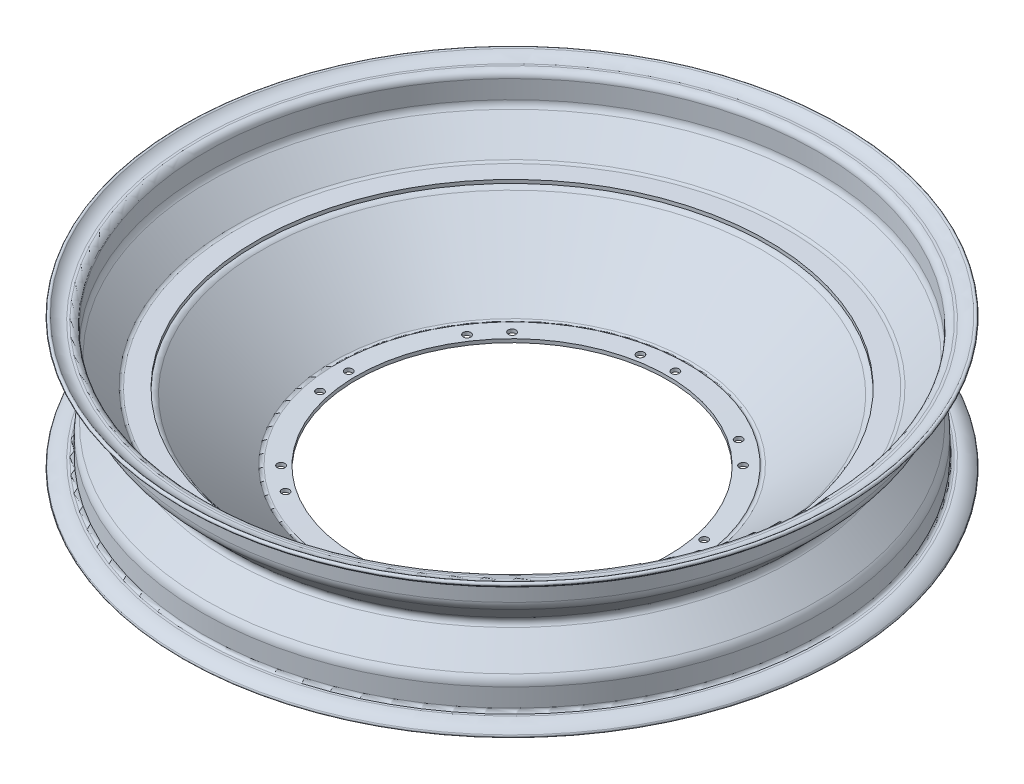
from build123d import *

# Parameters (mm, degrees)
SKETCH4_R               = 2.5
CUT_EXTRUDE3_DEPTH      = 41.899911875
CUT_EXTRUDE3_DEPTH_BACK = 48.292859511


with BuildPart() as part:
    # Sketch3 → Revolve2 (revolve)
    with BuildSketch(Plane.XY):
        with BuildLine():
            Line((-206.357183565, 37.167999668), (-204.857183475, 37.167999668))
            ThreePointArc((-204.857183475, 37.167999668), (-201.826523811, 35.912659332), (-200.571183475, 32.881999668))
            Line((-200.571183475, 32.881999668), (-200.571183475, 20.882001784))
            ThreePointArc((-200.571183475, 20.882001784), (-200.105263944, 18.622035193), (-198.783487479, 16.73062382))
            Line((-198.783487479, 16.73062382), (-182.043522604, -0.008977596))
            ThreePointArc((-182.043522604, -0.008977596), (-181.127338782, -0.617478113), (-180.048425839, -0.831049034))
            Line((-180.048425839, -0.831049034), (-167.29030635, -0.831049034))
            Line((-167.29030635, -0.831049034), (-167.290309661, -3.117049034))
            ThreePointArc((-167.290309661, -3.117049034), (-165.433325795, -3.465644725), (-163.82919026, -4.463971934))
            Line((-163.82919026, -4.463971934), (-117.404080958, -44.521079622))
            ThreePointArc((-117.404080958, -44.521079622), (-116.187448684, -45.004834199), (-114.932257648, -44.63239891))
            Line((-114.932257648, -44.63239891), (-102.000000909, -45.005569111))
            Line((-102.000000909, -45.005569111), (-102.000000909, -47.292520638))
            Line((-102.000000909, -47.292520638), (-114.383374161, -46.935188891))
            ThreePointArc((-114.383374161, -46.935188891), (-116.738970515, -47.244580095), (-118.897459215, -46.251864814))
            Line((-118.897459215, -46.251864814), (-165.352696521, -6.168761697))
            ThreePointArc((-165.352696521, -6.168761697), (-166.248595002, -5.601418118), (-167.29030635, -5.403049034))
            Line((-167.29030635, -5.403049034), (-180.048425839, -5.403049034))
            ThreePointArc((-180.048425839, -5.403049034), (-181.132186287, -5.618622356), (-182.050954083, -6.232523248))
            Line((-182.050954083, -6.232523248), (-198.81744055, -22.99900562))
            ThreePointArc((-198.81744055, -22.99900562), (-200.114496487, -24.879602157), (-200.571182545, -27.118002318))
            Line((-200.571182545, -27.118002318), (-200.571182545, -39.117999415))
            ThreePointArc((-200.571182545, -39.117999415), (-201.826522955, -42.148659258), (-204.857182798, -43.403999668))
            Line((-204.857182798, -43.403999668), (-206.357183565, -43.403999668))
            ThreePointArc((-206.357183565, -43.403999668), (-210.497320896, -44.280705684), (-213.926731129, -46.760321785))
            ThreePointArc((-213.926731129, -46.760321785), (-215.541213082, -46.839983719), (-215.620875016, -45.225501766))
            ThreePointArc((-215.620875016, -45.225501766), (-211.423926917, -42.190921656), (-206.357183565, -41.117999668))
            Line((-206.357183565, -41.117999668), (-204.857182798, -41.117999668))
            ThreePointArc((-204.857182798, -41.117999668), (-203.442969057, -40.532213156), (-202.857182545, -39.117999415))
            Line((-202.857182545, -39.117999415), (-202.857182545, -27.118001297))
            ThreePointArc((-202.857182545, -27.118001297), (-202.222549038, -23.995285341), (-200.419340997, -21.368013867))
            Line((-200.419340997, -21.368013867), (-184.996799867, -5.945476504))
            ThreePointArc((-184.996799867, -5.945476504), (-183.825226646, -3.117027566), (-184.996830227, -0.288591203))
            Line((-184.996830227, -0.288591203), (-200.37929842, 15.093543005))
            ThreePointArc((-200.37929842, 15.093543005), (-202.211669172, 17.733741575), (-202.857183475, 20.882001784))
            Line((-202.857183475, 20.882001784), (-202.857183475, 32.881999668))
            ThreePointArc((-202.857183475, 32.881999668), (-203.442969913, 34.296213231), (-204.857183475, 34.881999668))
            Line((-204.857183475, 34.881999668), (-206.357183565, 34.881999668))
            ThreePointArc((-206.357183565, 34.881999668), (-211.423926917, 35.954921656), (-215.620875016, 38.989501766))
            ThreePointArc((-215.620875016, 38.989501766), (-215.541213082, 40.603983719), (-213.926731129, 40.524321785))
            ThreePointArc((-213.926731129, 40.524321785), (-210.497320896, 38.044705684), (-206.357183565, 37.167999668))
        make_face()
    revolve(axis=Axis((0, 240.888952165, 0), (0, -1, 0)))

    # Sketch4 → Cut-Extrude3 (cut, two sides)
    with BuildSketch(Plane(origin=(0, 0, 0), x_dir=(1, 0, 0), z_dir=(0, 1, 0))) as cut_extrude3_sk:
        with Locations((0, 107)):
            Circle(SKETCH4_R)
        with Locations((-3884.181572475, -9484.24383099)):
            Circle(SKETCH4_R)
        with Locations((-13412.746254639, -13519.746254639)):
            Circle(SKETCH4_R)
        with Locations((-23003.990085629, -9635.564682164)):
            Circle(SKETCH4_R)
        with Locations((-27039.492509279, -107)):
            Circle(SKETCH4_R)
        with Locations((-23155.310936803, 9484.24383099)):
            Circle(SKETCH4_R)
        with Locations((-13626.746254639, 13519.746254639)):
            Circle(SKETCH4_R)
        with Locations((-4035.502423649, 9635.564682164)):
            Circle(SKETCH4_R)
        with Locations((-20.874664456, 104.944025003)):
            Circle(SKETCH4_R)
        with Locations((-3900.395983129, -9470.93700806)):
            Circle(SKETCH4_R)
        with Locations((-13414.802229636, -13498.871590184)):
            Circle(SKETCH4_R)
        with Locations((-22990.6832627, -9619.35027151)):
            Circle(SKETCH4_R)
        with Locations((-27018.617844823, -104.944025003)):
            Circle(SKETCH4_R)
        with Locations((-23139.096526149, 9470.93700806)):
            Circle(SKETCH4_R)
        with Locations((-13624.690279642, 13498.871590184)):
            Circle(SKETCH4_R)
        with Locations((-4048.809246579, 9619.35027151)):
            Circle(SKETCH4_R)
        with Locations((75.660425587, 75.660425587)):
            Circle(SKETCH4_R)
        with Locations((59.446014933, 88.967248516)):
            Circle(SKETCH4_R)
        with Locations((107, 0)):
            Circle(SKETCH4_R)
        with Locations((104.944025003, 20.874664456)):
            Circle(SKETCH4_R)
        with Locations((75.660425587, -75.660425587)):
            Circle(SKETCH4_R)
        with Locations((88.967248516, -59.446014933)):
            Circle(SKETCH4_R)
        with Locations((0, -107)):
            Circle(SKETCH4_R)
        with Locations((20.874664456, -104.944025003)):
            Circle(SKETCH4_R)
        with Locations((-75.660425587, -75.660425587)):
            Circle(SKETCH4_R)
        with Locations((-59.446014933, -88.967248516)):
            Circle(SKETCH4_R)
        with Locations((-107, 0)):
            Circle(SKETCH4_R)
        with Locations((-104.944025003, -20.874664456)):
            Circle(SKETCH4_R)
        with Locations((-75.660425587, 75.660425587)):
            Circle(SKETCH4_R)
        with Locations((-88.967248516, 59.446014933)):
            Circle(SKETCH4_R)
    extrude(amount=CUT_EXTRUDE3_DEPTH, mode=Mode.SUBTRACT)
    extrude(cut_extrude3_sk.sketch, amount=-CUT_EXTRUDE3_DEPTH_BACK, mode=Mode.SUBTRACT)


solid = part.part
